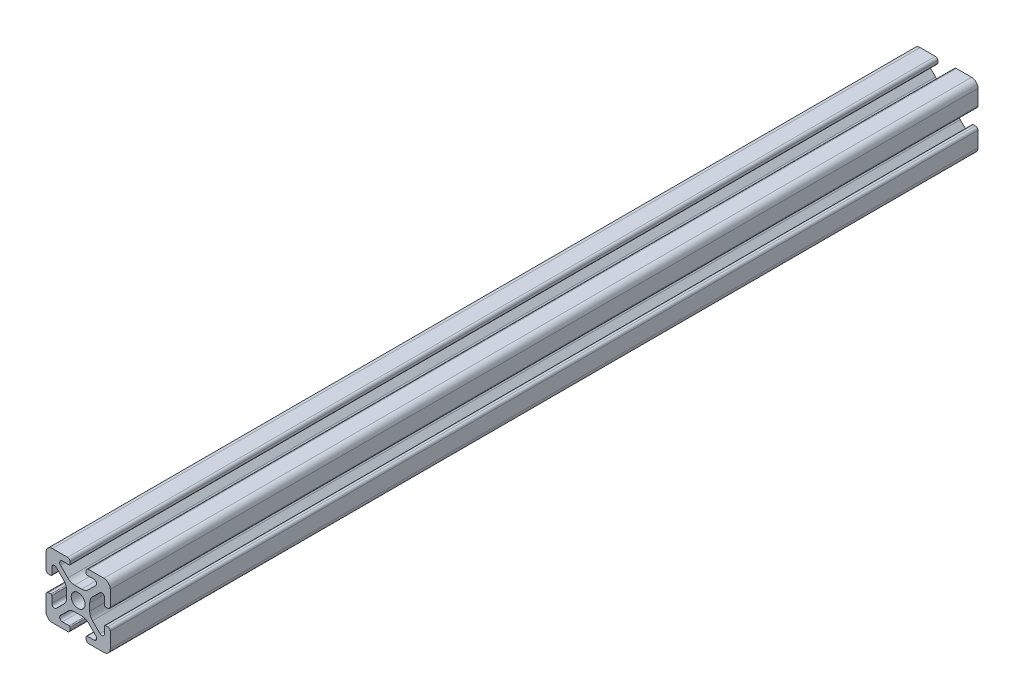
from build123d import *

# Parameters (mm, degrees)
SKETCH3_R                = 2.15
BOSS_EXTRUDE1_DEPTH      = 135
BOSS_EXTRUDE1_DEPTH_BACK = 135


with BuildPart() as part:
    # Sketch3 → Boss-Extrude1 (new body, two sides)
    with BuildSketch(Plane.XY) as boss_extrude1_sk:
        with BuildLine():
            Line((3.2874, 10), (8, 10))
            ThreePointArc((8, 10), (9.414213562, 9.414213562), (10, 8))
            Line((10, 8), (10, 3.2874))
            ThreePointArc((10, 3.2874), (9.76937588, 2.73062412), (9.2126, 2.5))
            Line((9.2126, 2.5), (8.5048, 2.5))
            ThreePointArc((8.5048, 2.5), (8.289273853, 2.589273853), (8.2, 2.8048))
            Line((8.2, 2.8048), (8.2, 4.9118))
            ThreePointArc((8.2, 4.9118), (7.682565253, 5.686195824), (6.769103096, 5.504496904))
            Line((6.769103096, 5.504496904), (4.478679656, 3.214073464))
            ThreePointArc((4.478679656, 3.214073464), (3.828361402, 2.240803418), (3.6, 1.092753121))
            Line((3.6, 1.092753121), (3.6, -1.092753121))
            ThreePointArc((3.6, -1.092753121), (3.828361402, -2.240803418), (4.478679656, -3.214073464))
            Line((4.478679656, -3.214073464), (6.769103096, -5.504496904))
            ThreePointArc((6.769103096, -5.504496904), (7.682565253, -5.686195824), (8.2, -4.9118))
            Line((8.2, -4.9118), (8.2, -2.8048))
            ThreePointArc((8.2, -2.8048), (8.289273853, -2.589273853), (8.5048, -2.5))
            Line((8.5048, -2.5), (9.2126, -2.5))
            ThreePointArc((9.2126, -2.5), (9.76937588, -2.73062412), (10, -3.2874))
            Line((10, -3.2874), (10, -8))
            ThreePointArc((10, -8), (9.414213562, -9.414213562), (8, -10))
            Line((8, -10), (3.2874, -10))
            ThreePointArc((3.2874, -10), (2.73062412, -9.76937588), (2.5, -9.2126))
            Line((2.5, -9.2126), (2.5, -8.5048))
            ThreePointArc((2.5, -8.5048), (2.589273853, -8.289273853), (2.8048, -8.2))
            Line((2.8048, -8.2), (4.9118, -8.2))
            ThreePointArc((4.9118, -8.2), (5.686195824, -7.682565253), (5.504496904, -6.769103096))
            Line((5.504496904, -6.769103096), (3.214073464, -4.478679656))
            ThreePointArc((3.214073464, -4.478679656), (2.240803418, -3.828361402), (1.092753121, -3.6))
            Line((1.092753121, -3.6), (-1.092753121, -3.6))
            ThreePointArc((-1.092753121, -3.6), (-2.240803418, -3.828361402), (-3.214073464, -4.478679656))
            Line((-3.214073464, -4.478679656), (-5.504496904, -6.769103096))
            ThreePointArc((-5.504496904, -6.769103096), (-5.686195824, -7.682565253), (-4.9118, -8.2))
            Line((-4.9118, -8.2), (-2.8048, -8.2))
            ThreePointArc((-2.8048, -8.2), (-2.589273853, -8.289273853), (-2.5, -8.5048))
            Line((-2.5, -8.5048), (-2.5, -9.2126))
            ThreePointArc((-2.5, -9.2126), (-2.73062412, -9.76937588), (-3.2874, -10))
            Line((-3.2874, -10), (-8, -10))
            ThreePointArc((-8, -10), (-9.414213562, -9.414213562), (-10, -8))
            Line((-10, -8), (-10, -3.2874))
            ThreePointArc((-10, -3.2874), (-9.76937588, -2.73062412), (-9.2126, -2.5))
            Line((-9.2126, -2.5), (-8.5048, -2.5))
            ThreePointArc((-8.5048, -2.5), (-8.289273853, -2.589273853), (-8.2, -2.8048))
            Line((-8.2, -2.8048), (-8.2, -4.9118))
            ThreePointArc((-8.2, -4.9118), (-7.682565253, -5.686195824), (-6.769103096, -5.504496904))
            Line((-6.769103096, -5.504496904), (-4.478679656, -3.214073464))
            ThreePointArc((-4.478679656, -3.214073464), (-3.828361402, -2.240803418), (-3.6, -1.092753121))
            Line((-3.6, -1.092753121), (-3.6, 1.092753121))
            ThreePointArc((-3.6, 1.092753121), (-3.828361402, 2.240803418), (-4.478679656, 3.214073464))
            Line((-4.478679656, 3.214073464), (-6.769103096, 5.504496904))
            ThreePointArc((-6.769103096, 5.504496904), (-7.682565253, 5.686195824), (-8.2, 4.9118))
            Line((-8.2, 4.9118), (-8.2, 2.8048))
            ThreePointArc((-8.2, 2.8048), (-8.289273853, 2.589273853), (-8.5048, 2.5))
            Line((-8.5048, 2.5), (-9.2126, 2.5))
            ThreePointArc((-9.2126, 2.5), (-9.76937588, 2.73062412), (-10, 3.2874))
            Line((-10, 3.2874), (-10, 8))
            ThreePointArc((-10, 8), (-9.414213562, 9.414213562), (-8, 10))
            Line((-8, 10), (-3.2874, 10))
            ThreePointArc((-3.2874, 10), (-2.73062412, 9.76937588), (-2.5, 9.2126))
            Line((-2.5, 9.2126), (-2.5, 8.5048))
            ThreePointArc((-2.5, 8.5048), (-2.589273853, 8.289273853), (-2.8048, 8.2))
            Line((-2.8048, 8.2), (-4.9118, 8.2))
            ThreePointArc((-4.9118, 8.2), (-5.686195824, 7.682565253), (-5.504496904, 6.769103096))
            Line((-5.504496904, 6.769103096), (-3.214073464, 4.478679656))
            ThreePointArc((-3.214073464, 4.478679656), (-2.240803418, 3.828361402), (-1.092753121, 3.6))
            Line((-1.092753121, 3.6), (1.092753121, 3.6))
            ThreePointArc((1.092753121, 3.6), (2.240803418, 3.828361402), (3.214073464, 4.478679656))
            Line((3.214073464, 4.478679656), (5.504496904, 6.769103096))
            ThreePointArc((5.504496904, 6.769103096), (5.686195824, 7.682565253), (4.9118, 8.2))
            Line((4.9118, 8.2), (2.8048, 8.2))
            ThreePointArc((2.8048, 8.2), (2.589273853, 8.289273853), (2.5, 8.5048))
            Line((2.5, 8.5048), (2.5, 9.2126))
            ThreePointArc((2.5, 9.2126), (2.73062412, 9.76937588), (3.2874, 10))
        make_face()
        Circle(SKETCH3_R, mode=Mode.SUBTRACT)
    extrude(amount=BOSS_EXTRUDE1_DEPTH)
    extrude(boss_extrude1_sk.sketch, amount=-BOSS_EXTRUDE1_DEPTH_BACK)


solid = part.part
